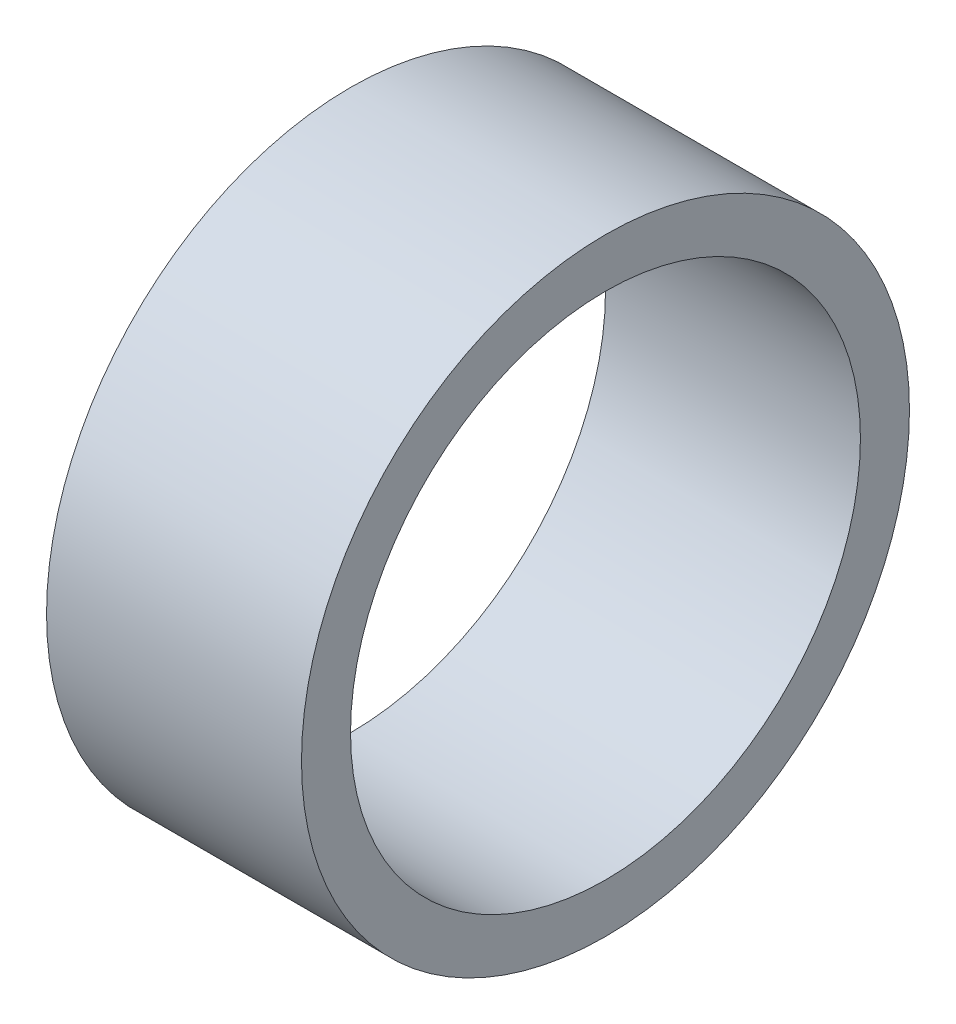
from build123d import *

# Parameters (mm, degrees)
SKETCH1_R           = 31
SKETCH1_R_2         = 26
BOSS_EXTRUDE1_DEPTH = 26


with BuildPart() as part:
    # Sketch1 → Boss-Extrude1 (new body)
    with BuildSketch(Plane(origin=(0, 0, 0), x_dir=(0, 0, -1), z_dir=(1, 0, 0))):
        Circle(SKETCH1_R)
        Circle(SKETCH1_R_2, mode=Mode.SUBTRACT)
    extrude(amount=BOSS_EXTRUDE1_DEPTH)


solid = part.part
